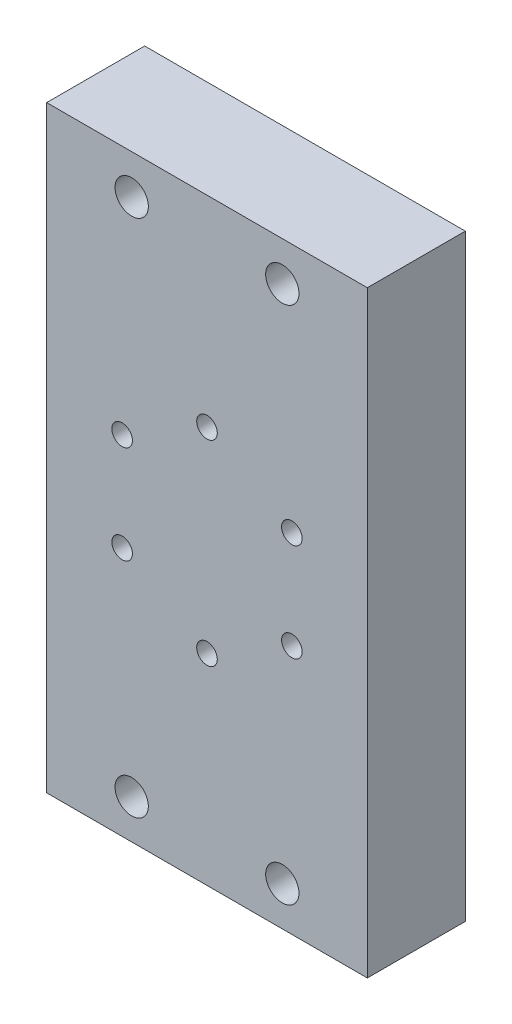
from build123d import *

# Parameters (mm, degrees)
SKETCH1_W                  = 65.44
SKETCH1_H                  = 122
BOSS_EXTRUDE1_DEPTH        = 20
M5X0_8_TAPPED_HOLE1_D      = 4.2
M5X0_8_TAPPED_HOLE1_DEPTH  = 20
M8X1_25_TAPPED_HOLE1_D     = 6.8
M8X1_25_TAPPED_HOLE1_DEPTH = 20


with BuildPart() as part:
    # Sketch1 → Boss-Extrude1 (new body)
    with BuildSketch(Plane.XY):
        Rectangle(SKETCH1_W, SKETCH1_H)
    extrude(amount=BOSS_EXTRUDE1_DEPTH)

    # M5x0.8 Tapped Hole1
    with Locations(Plane.XY.offset(20)):
        with Locations((0, 20), (-17.320508076, 10), (-17.320508076, -10), (0, -20), (17.320508076, -10), (17.320508076, 10)):
            Hole(M5X0_8_TAPPED_HOLE1_D / 2, depth=M5X0_8_TAPPED_HOLE1_DEPTH)

    # M8x1.25 Tapped Hole1
    with Locations(Plane.XY.offset(20)):
        with Locations((-15.37, 53), (15.37, 53), (15.37, -53), (-15.37, -53)):
            Hole(M8X1_25_TAPPED_HOLE1_D / 2, depth=M8X1_25_TAPPED_HOLE1_DEPTH)


solid = part.part
